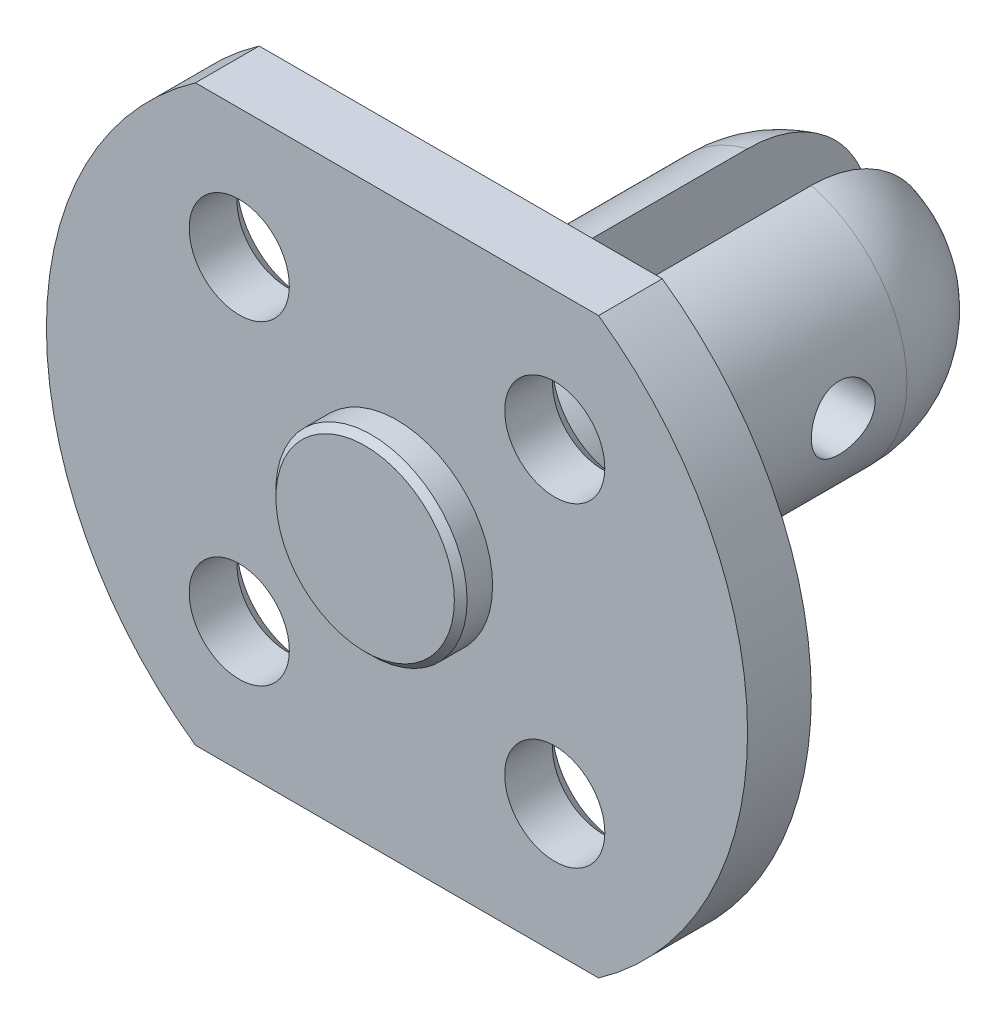
from build123d import *

# Parameters (mm, degrees)
BOSS_EXTRUDE1_DEPTH = 2
SKETCH2_R           = 1.571161349
CUT_EXTRUDE1_DEPTH  = 2
CHAMFER1_SIZE       = 0.5
SKETCH4_W           = 2
SKETCH4_H           = 12.352861416
CUT_EXTRUDE2_DEPTH  = 13.5
SKETCH5_R           = 1
CUT_EXTRUDE3_DEPTH  = 13.5
SKETCH6_R           = 3
BOSS_EXTRUDE2_DEPTH = 1
CHAMFER2_SIZE       = 0.2


with BuildPart() as part:
    # Sketch1 → Boss-Extrude1 (new body)
    with BuildSketch(Plane.XY):
        with BuildLine():
            Line((-6.32455532, 9), (6.32455532, 9))
            ThreePointArc((6.32455532, 9), (11, 0), (6.32455532, -9))
            Line((6.32455532, -9), (-6.32455532, -9))
            ThreePointArc((-6.32455532, -9), (-11, 0), (-6.32455532, 9))
        make_face()
    extrude(amount=BOSS_EXTRUDE1_DEPTH)

    # Sketch2 → Cut-Extrude1 (cut)
    with BuildSketch(Plane.XY.offset(2)):
        with Locations((4.949747468, 4.949747468)):
            Circle(SKETCH2_R)
        with Locations((4.949747468, -4.949747468)):
            Circle(SKETCH2_R)
        with Locations((-4.949747468, -4.949747468)):
            Circle(SKETCH2_R)
        with Locations((-4.949747468, 4.949747468)):
            Circle(SKETCH2_R)
    extrude(amount=-CUT_EXTRUDE1_DEPTH, mode=Mode.SUBTRACT)

    # Chamfer1
    chamfer1_edges = [part.edges().sort_by_distance(p)[0] for p in [
        (-6.520908817, 4.949747468, 0),
        (-6.520908817, -4.949747468, 0),
        (3.378586119, -4.949747468, 0),
        (3.378586119, 4.949747468, 0),
    ]]
    chamfer(chamfer1_edges, length=CHAMFER1_SIZE)

    # Sketch3 → Revolve1 (revolve)
    with BuildSketch(Plane(origin=(0, 0, 0), x_dir=(1, 0, 0), z_dir=(0, 1, 0))):
        with BuildLine():
            Line((0, 0), (0, 14))
            ThreePointArc((0, 14), (2.828427125, 12.828427125), (4, 10))
            Line((4, 10), (4, 0))
            Line((4, 0), (0, 0))
        make_face()
    revolve(axis=Axis((0, 0, 0), (0, 0, -1)))

    # Sketch4 → Cut-Extrude2 (cut, symmetric)
    with BuildSketch(Plane(origin=(0, 0, 0), x_dir=(1, 0, 0), z_dir=(0, 1, 0))):
        with Locations((0, 9.676430708)):
            Rectangle(SKETCH4_W, SKETCH4_H)
    extrude(amount=CUT_EXTRUDE2_DEPTH, both=True, mode=Mode.SUBTRACT)

    # Sketch5 → Cut-Extrude3 (cut, symmetric)
    with BuildSketch(Plane(origin=(0, 0, 0), x_dir=(0, 0, -1), z_dir=(1, 0, 0))):
        with Locations((8, 0)):
            Circle(SKETCH5_R)
    extrude(amount=CUT_EXTRUDE3_DEPTH, both=True, mode=Mode.SUBTRACT)

    # Sketch6 → Boss-Extrude2 (add)
    with BuildSketch(Plane.XY.offset(2)):
        Circle(SKETCH6_R)
    extrude(amount=BOSS_EXTRUDE2_DEPTH)

    # Chamfer2
    chamfer2_edges = [part.edges().sort_by_distance(p)[0] for p in [
        (-3, 0, 3),
    ]]
    chamfer(chamfer2_edges, length=CHAMFER2_SIZE)


solid = part.part
